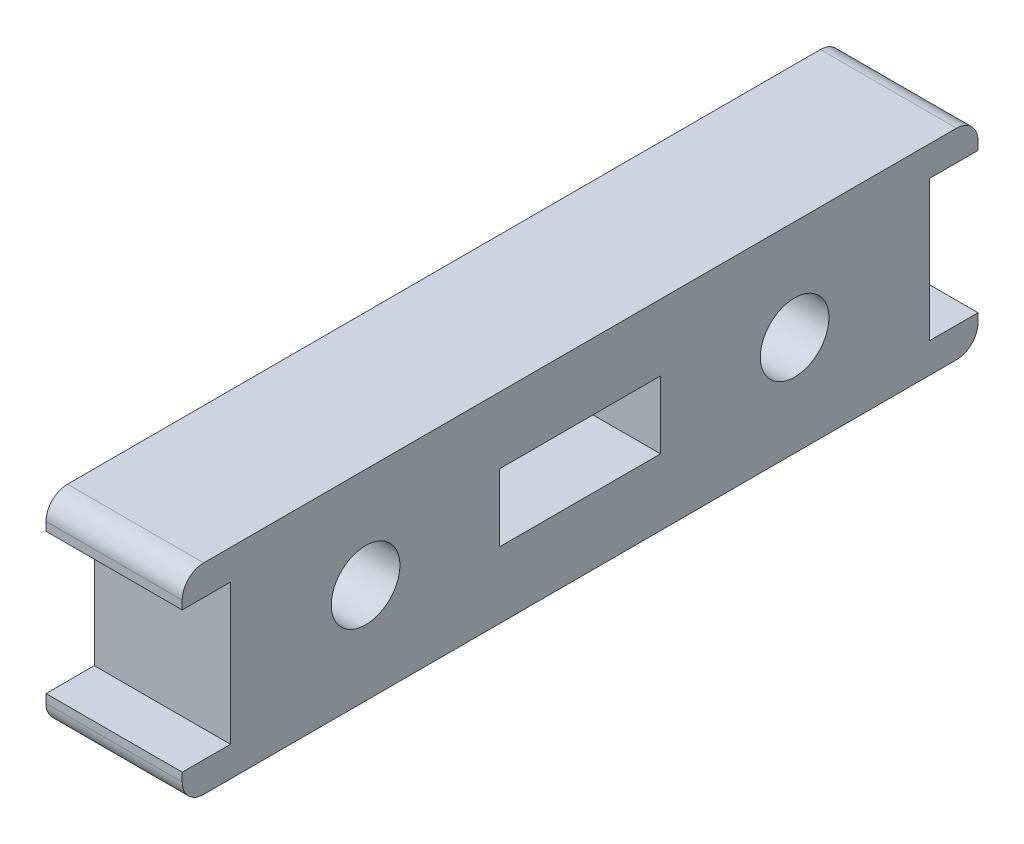
from build123d import *

# Parameters (mm, degrees)
BOSS_EXTRUDE1_DEPTH            = 6.35
FILLET1_R                      = 1
SKETCH2_W                      = 7.5
SKETCH2_H                      = 3.15
CUT_EXTRUDE1_DEPTH             = 7.35
F_3_2_3_2_DIAMETER_HOLE1_D     = 3.2
F_3_2_3_2_DIAMETER_HOLE1_DEPTH = 6.35
F_3_2_3_2_DIAMETER_HOLE2_D     = 3.2
F_3_2_3_2_DIAMETER_HOLE2_DEPTH = 6.35


with BuildPart() as part:
    # Sketch1 → Boss-Extrude1 (new body)
    with BuildSketch(Plane(origin=(6.35, 0, 0), x_dir=(0, 0, -1), z_dir=(1, 0, 0))):
        Polygon((37.1, -7.95), (34.85, -7.95), (34.85, -1.4), (37.1, -1.4), (37.1, 0), (0, 0), (0, -1.4), (2.25, -1.4), (2.25, -7.95), (0, -7.95), (0, -9.35), (37.1, -9.35), align=None)
    extrude(amount=-BOSS_EXTRUDE1_DEPTH)

    # Fillet1
    fillet1_edges = [part.edges().sort_by_distance(p)[0] for p in [
        (3.175, -9.35, -37.1),
        (3.175, -9.35, 0),
        (3.175, 0, 0),
        (3.175, 0, -37.1),
    ]]
    fillet(fillet1_edges, radius=FILLET1_R)

    # Sketch2 → Cut-Extrude1 (cut, through all)
    with BuildSketch(Plane.ZY):
        with Locations((-18.55, -4.675)):
            Rectangle(SKETCH2_W, SKETCH2_H)
    extrude(amount=-CUT_EXTRUDE1_DEPTH, mode=Mode.SUBTRACT)

    # Ø3.2 (3.2) Diameter Hole1
    with Locations(Plane(origin=(6.35, 0, 0), x_dir=(0, 0, -1), z_dir=(1, 0, 0))):
        with Locations((28.55, -4.675)):
            Hole(F_3_2_3_2_DIAMETER_HOLE1_D / 2, depth=F_3_2_3_2_DIAMETER_HOLE1_DEPTH)

    # Ø3.2 (3.2) Diameter Hole2
    with Locations(Plane(origin=(6.35, 0, 0), x_dir=(0, 0, -1), z_dir=(1, 0, 0))):
        with Locations((8.55, -4.675)):
            Hole(F_3_2_3_2_DIAMETER_HOLE2_D / 2, depth=F_3_2_3_2_DIAMETER_HOLE2_DEPTH)


solid = part.part
